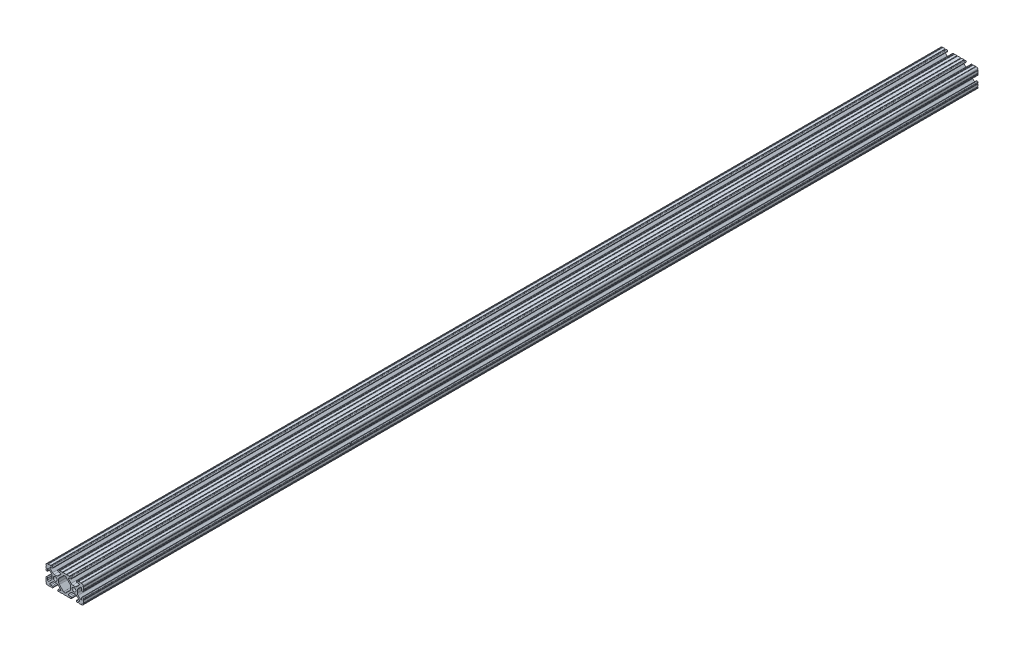
from build123d import *

# Parameters (mm, degrees)
SKETCH1_R               = 2.6035
BOSS_EXTRUDE1_DEPTH     = 609.6
SKETCH2_R               = 3.5
CUT_EXTRUDE1_DEPTH      = 9.191498123
CUT_EXTRUDE1_DEPTH_BACK = 43.608501877


with BuildPart() as part:
    # Sketch1 → Boss-Extrude1 (new body, symmetric)
    with BuildSketch(Plane.XY):
        with BuildLine():
            Line((18.01710265, 12.7), (16.98745015, 12.7))
            ThreePointArc((16.98745015, 12.7), (16.245730386, 12.392769614), (15.9385, 11.65104985))
            Line((15.9385, 11.65104985), (15.9385, 11.53922))
            ThreePointArc((15.9385, 11.53922), (16.245750844, 10.797450844), (16.98752, 10.4902))
            Line((16.98752, 10.4902), (19.116384363, 10.4902))
            ThreePointArc((19.116384363, 10.4902), (20.052502933, 9.869096983), (19.844087081, 8.765172272))
            Line((19.844087081, 8.765172272), (16.618993479, 5.455112286))
            ThreePointArc((16.618993479, 5.455112286), (15.578994274, 4.745442459), (14.344932584, 4.4958))
            Line((14.344932584, 4.4958), (11.083317835, 4.4958))
            ThreePointArc((11.083317835, 4.4958), (9.854330953, 4.743306833), (8.816955189, 5.447238587))
            Line((8.816955189, 5.447238587), (5.564154119, 8.762652677))
            ThreePointArc((5.564154119, 8.762652677), (5.352591412, 9.867473037), (6.289393385, 10.4902))
            Line((6.289393385, 10.4902), (8.41248, 10.4902))
            ThreePointArc((8.41248, 10.4902), (9.154249156, 10.797450844), (9.4615, 11.53922))
            Line((9.4615, 11.53922), (9.4615, 11.65104985))
            ThreePointArc((9.4615, 11.65104985), (9.154269614, 12.392769614), (8.41254985, 12.7))
            Line((8.41254985, 12.7), (7.38288465, 12.7))
            ThreePointArc((7.38288465, 12.7), (6.87488465, 12.192), (6.36688465, 12.7))
            Line((6.36688465, 12.7), (3.14958095, 12.7))
            ThreePointArc((3.14958095, 12.7), (2.64158095, 12.192), (2.13358095, 12.7))
            Line((2.13358095, 12.7), (-2.13358095, 12.7))
            ThreePointArc((-2.13358095, 12.7), (-2.64158095, 12.192), (-3.14958095, 12.7))
            Line((-3.14958095, 12.7), (-6.36689735, 12.7))
            ThreePointArc((-6.36689735, 12.7), (-6.87489735, 12.192), (-7.38289735, 12.7))
            Line((-7.38289735, 12.7), (-8.41254985, 12.7))
            ThreePointArc((-8.41254985, 12.7), (-9.154269614, 12.392769614), (-9.4615, 11.65104985))
            Line((-9.4615, 11.65104985), (-9.4615, 11.53922))
            ThreePointArc((-9.4615, 11.53922), (-9.154249156, 10.797450844), (-8.41248, 10.4902))
            Line((-8.41248, 10.4902), (-6.283641037, 10.4902))
            ThreePointArc((-6.283641037, 10.4902), (-5.297291557, 9.829633109), (-5.532576693, 8.666071843))
            Line((-5.532576693, 8.666071843), (-8.809985098, 5.416263103))
            ThreePointArc((-8.809985098, 5.416263103), (-9.836720513, 4.734920264), (-11.045536121, 4.4958))
            Line((-11.045536121, 4.4958), (-14.354463879, 4.4958))
            ThreePointArc((-14.354463879, 4.4958), (-15.563279487, 4.734920264), (-16.590014902, 5.416263103))
            Line((-16.590014902, 5.416263103), (-19.867423307, 8.666071843))
            ThreePointArc((-19.867423307, 8.666071843), (-20.102708443, 9.829633109), (-19.116358963, 10.4902))
            Line((-19.116358963, 10.4902), (-16.98752, 10.4902))
            ThreePointArc((-16.98752, 10.4902), (-16.245750844, 10.797450844), (-15.9385, 11.53922))
            Line((-15.9385, 11.53922), (-15.9385, 11.65104985))
            ThreePointArc((-15.9385, 11.65104985), (-16.245730386, 12.392769614), (-16.98745015, 12.7))
            Line((-16.98745015, 12.7), (-18.01711535, 12.7))
            ThreePointArc((-18.01711535, 12.7), (-18.52511535, 12.192), (-19.03311535, 12.7))
            Line((-19.03311535, 12.7), (-22.2504, 12.7))
            ThreePointArc((-22.2504, 12.7), (-22.758323491, 12.192000006), (-23.266399977, 12.699846982))
            ThreePointArc((-23.266399977, 12.699846982), (-24.782522516, 12.082522516), (-25.399846982, 10.566399977))
            ThreePointArc((-25.399846982, 10.566399977), (-24.892000006, 10.058323491), (-25.4, 9.5504))
            Line((-25.4, 9.5504), (-25.4, 6.3330836))
            ThreePointArc((-25.4, 6.3330836), (-24.892, 5.8250836), (-25.4, 5.3170836))
            Line((-25.4, 5.3170836), (-25.4, 4.237520184))
            ThreePointArc((-25.4, 4.237520184), (-25.107393763, 3.531106237), (-24.400979816, 3.2385))
            Line((-24.400979816, 3.2385), (-24.23922, 3.2385))
            ThreePointArc((-24.23922, 3.2385), (-23.497450844, 3.545750844), (-23.1902, 4.28752))
            Line((-23.1902, 4.28752), (-23.1902, 6.334741132))
            ThreePointArc((-23.1902, 6.334741132), (-22.556026952, 7.286023527), (-21.434002553, 7.066535717))
            Line((-21.434002553, 7.066535717), (-18.147950853, 3.808156468))
            ThreePointArc((-18.147950853, 3.808156468), (-17.452759693, 2.774838327), (-17.208501877, 1.553619571))
            Line((-17.208501877, 1.553619571), (-17.208501877, -1.695179196))
            ThreePointArc((-17.208501877, -1.695179196), (-17.450738657, -2.911536421), (-18.140486065, -3.942289578))
            Line((-18.140486065, -3.942289578), (-21.431579576, -7.227386226))
            ThreePointArc((-21.431579576, -7.227386226), (-22.55444896, -7.449940594), (-23.1902, -6.498002195))
            Line((-23.1902, -6.498002195), (-23.1902, -4.28752))
            ThreePointArc((-23.1902, -4.28752), (-23.497450844, -3.545750844), (-24.23922, -3.2385))
            Line((-24.23922, -3.2385), (-24.35098, -3.2385))
            ThreePointArc((-24.35098, -3.2385), (-25.092749156, -3.545750844), (-25.4, -4.28752))
            Line((-25.4, -4.28752), (-25.4, -5.3171344))
            ThreePointArc((-25.4, -5.3171344), (-24.892, -5.8251344), (-25.4, -6.3331344))
            Line((-25.4, -6.3331344), (-25.4, -9.5504))
            ThreePointArc((-25.4, -9.5504), (-24.892000006, -10.058323491), (-25.399846982, -10.566399977))
            ThreePointArc((-25.399846982, -10.566399977), (-24.782522516, -12.082522516), (-23.266399977, -12.699846982))
            ThreePointArc((-23.266399977, -12.699846982), (-22.758323491, -12.192000006), (-22.2504, -12.7))
            Line((-22.2504, -12.7), (-19.03308995, -12.7))
            ThreePointArc((-19.03308995, -12.7), (-18.52508995, -12.192), (-18.01708995, -12.7))
            Line((-18.01708995, -12.7), (-16.9874692, -12.7))
            ThreePointArc((-16.9874692, -12.7), (-16.245700044, -12.392749156), (-15.9384492, -11.65098))
            Line((-15.9384492, -11.65098), (-15.9384492, -11.53922))
            ThreePointArc((-15.9384492, -11.53922), (-16.245700044, -10.797450844), (-16.9874692, -10.4902))
            Line((-16.9874692, -10.4902), (-19.116358963, -10.4902))
            ThreePointArc((-19.116358963, -10.4902), (-20.055197748, -9.862578342), (-19.834124023, -8.755124678))
            Line((-19.834124023, -8.755124678), (-16.49660751, -5.423689618))
            ThreePointArc((-16.49660751, -5.423689618), (-15.467274017, -4.736928798), (-14.253591699, -4.4958))
            Line((-14.253591699, -4.4958), (-11.146408301, -4.4958))
            ThreePointArc((-11.146408301, -4.4958), (-9.932725983, -4.736928798), (-8.90339249, -5.423689618))
            Line((-8.90339249, -5.423689618), (-5.565875977, -8.755124678))
            ThreePointArc((-5.565875977, -8.755124678), (-5.344802252, -9.862578342), (-6.283641037, -10.4902))
            Line((-6.283641037, -10.4902), (-8.4125308, -10.4902))
            ThreePointArc((-8.4125308, -10.4902), (-9.154299956, -10.797450844), (-9.4615508, -11.53922))
            Line((-9.4615508, -11.53922), (-9.4615508, -11.65098))
            ThreePointArc((-9.4615508, -11.65098), (-9.154299956, -12.392749156), (-8.4125308, -12.7))
            Line((-8.4125308, -12.7), (-7.38287195, -12.7))
            ThreePointArc((-7.38287195, -12.7), (-6.87487195, -12.192), (-6.36687195, -12.7))
            Line((-6.36687195, -12.7), (-3.14960635, -12.7))
            ThreePointArc((-3.14960635, -12.7), (-2.64160635, -12.192), (-2.13360635, -12.7))
            Line((-2.13360635, -12.7), (2.13360635, -12.7))
            ThreePointArc((2.13360635, -12.7), (2.64159365, -12.1920127), (3.14958095, -12.7))
            Line((3.14958095, -12.7), (6.36691005, -12.7))
            ThreePointArc((6.36691005, -12.7), (6.87491005, -12.192), (7.38291005, -12.7))
            Line((7.38291005, -12.7), (8.4125308, -12.7))
            ThreePointArc((8.4125308, -12.7), (9.154299956, -12.392749156), (9.4615508, -11.65098))
            Line((9.4615508, -11.65098), (9.4615508, -11.53922))
            ThreePointArc((9.4615508, -11.53922), (9.154299956, -10.797450844), (8.4125308, -10.4902))
            Line((8.4125308, -10.4902), (6.289393385, -10.4902))
            ThreePointArc((6.289393385, -10.4902), (5.231590322, -9.783049717), (5.480677245, -8.535265862))
            Line((5.480677245, -8.535265862), (8.597933595, -5.423689618))
            ThreePointArc((8.597933595, -5.423689618), (9.627267088, -4.736928798), (10.840949406, -4.4958))
            Line((10.840949406, -4.4958), (14.102564155, -4.4958))
            ThreePointArc((14.102564155, -4.4958), (15.215927525, -4.697410182), (16.187895372, -5.276636531))
            Line((16.187895372, -5.276636531), (19.868247549, -8.482246082))
            ThreePointArc((19.868247549, -8.482246082), (20.188435806, -9.746879864), (19.116384363, -10.4902))
            Line((19.116384363, -10.4902), (16.9874692, -10.4902))
            ThreePointArc((16.9874692, -10.4902), (16.245700044, -10.797450844), (15.9384492, -11.53922))
            Line((15.9384492, -11.53922), (15.9384492, -11.65098))
            ThreePointArc((15.9384492, -11.65098), (16.245700044, -12.392749156), (16.9874692, -12.7))
            Line((16.9874692, -12.7), (18.01710265, -12.7))
            ThreePointArc((18.01710265, -12.7), (18.52510265, -12.192), (19.03310265, -12.7))
            Line((19.03310265, -12.7), (22.2504, -12.7))
            ThreePointArc((22.2504, -12.7), (22.758323491, -12.192000006), (23.266399977, -12.699846982))
            ThreePointArc((23.266399977, -12.699846982), (24.782522516, -12.082522516), (25.399846982, -10.566399977))
            ThreePointArc((25.399846982, -10.566399977), (24.892000006, -10.058323492), (25.4, -9.550400001))
            Line((25.4, -9.550400001), (25.4, -6.333083592))
            ThreePointArc((25.4, -6.333083592), (24.892000001, -5.825083593), (25.4, -5.317083593))
            Line((25.4, -5.317083593), (25.4, -4.237520184))
            ThreePointArc((25.4, -4.237520184), (25.107393763, -3.531106237), (24.400979816, -3.2385))
            Line((24.400979816, -3.2385), (24.189220184, -3.2385))
            ThreePointArc((24.189220184, -3.2385), (23.482806237, -3.531106237), (23.1902, -4.237520184))
            Line((23.1902, -4.237520184), (23.1902, -6.155876159))
            ThreePointArc((23.1902, -6.155876159), (22.62232736, -7.038258539), (21.583974541, -6.886926384))
            Line((21.583974541, -6.886926384), (18.29817066, -4.024970844))
            ThreePointArc((18.29817066, -4.024970844), (17.493730985, -2.946044689), (17.208501877, -1.630807374))
            Line((17.208501877, -1.630807374), (17.208501877, 1.630807374))
            ThreePointArc((17.208501877, 1.630807374), (17.442348332, 2.82673414), (18.109440981, 3.846495088))
            Line((18.109440981, 3.846495088), (21.526346532, 7.353420386))
            ThreePointArc((21.526346532, 7.353420386), (22.585896263, 7.574939077), (23.1902, 6.676867167))
            Line((23.1902, 6.676867167), (23.1902, 4.237520184))
            ThreePointArc((23.1902, 4.237520184), (23.482806237, 3.531106237), (24.189220184, 3.2385))
            Line((24.189220184, 3.2385), (24.400979816, 3.2385))
            ThreePointArc((24.400979816, 3.2385), (25.107393763, 3.531106237), (25.4, 4.237520184))
            Line((25.4, 4.237520184), (25.4, 5.3170836))
            ThreePointArc((25.4, 5.3170836), (24.891949193, 5.825134407), (25.4, 6.333185215))
            Line((25.4, 6.333185215), (25.4, 9.550400015))
            ThreePointArc((25.4, 9.550400015), (24.892000013, 10.058323498), (25.399846982, 10.566399977))
            ThreePointArc((25.399846982, 10.566399977), (24.782522516, 12.082522516), (23.266399977, 12.699846982))
            ThreePointArc((23.266399977, 12.699846982), (22.758323491, 12.192000006), (22.2504, 12.7))
            Line((22.2504, 12.7), (19.03310265, 12.7))
            ThreePointArc((19.03310265, 12.7), (18.52510265, 12.192), (18.01710265, 12.7))
        make_face()
        with Locations((-12.7, 0)):
            Circle(SKETCH1_R, mode=Mode.SUBTRACT)
        with Locations((12.7, 0)):
            Circle(SKETCH1_R, mode=Mode.SUBTRACT)
        with BuildLine():
            Line((-7.259513935, -3.869413038), (-1.545748891, -9.572766749))
            ThreePointArc((-1.545748891, -9.572766749), (-1.035199478, -9.913400116), (-0.433213048, -10.033))
            Line((-0.433213048, -10.033), (0.433213048, -10.033))
            ThreePointArc((0.433213048, -10.033), (1.035199478, -9.913400116), (1.545748891, -9.572766749))
            Line((1.545748891, -9.572766749), (7.259513935, -3.869413038))
            ThreePointArc((7.259513935, -3.869413038), (7.949261343, -2.838659881), (8.191498123, -1.622302656))
            Line((8.191498123, -1.622302656), (8.191498123, 1.622302656))
            ThreePointArc((8.191498123, 1.622302656), (7.955573352, 2.823327967), (7.282860769, 3.845864069))
            Line((7.282860769, 3.845864069), (1.675572808, 9.561086461))
            ThreePointArc((1.675572808, 9.561086461), (1.161034429, 9.910236611), (0.551456936, 10.033))
            Line((0.551456936, 10.033), (-0.395199982, 10.033))
            ThreePointArc((-0.395199982, 10.033), (-0.994772524, 9.914396349), (-1.50403329, 9.576450301))
            Line((-1.50403329, 9.576450301), (-7.252049147, 3.876839553))
            ThreePointArc((-7.252049147, 3.876839553), (-7.947240307, 2.843521412), (-8.191498123, 1.622302656))
            Line((-8.191498123, 1.622302656), (-8.191498123, -1.622302656))
            ThreePointArc((-8.191498123, -1.622302656), (-7.949261343, -2.838659881), (-7.259513935, -3.869413038))
        make_face(mode=Mode.SUBTRACT)
    extrude(amount=BOSS_EXTRUDE1_DEPTH, both=True)

    # Sketch2 → Cut-Extrude1 (cut, two sides)
    with BuildSketch(Plane(origin=(17.208501877, 0, 0), x_dir=(0, 0, -1), z_dir=(1, 0, 0))) as cut_extrude1_sk:
        with Locations((244.47, 0)):
            Circle(SKETCH2_R)
        with Locations((-244.47, 0)):
            Circle(SKETCH2_R)
    extrude(amount=CUT_EXTRUDE1_DEPTH, mode=Mode.SUBTRACT)
    extrude(cut_extrude1_sk.sketch, amount=-CUT_EXTRUDE1_DEPTH_BACK, mode=Mode.SUBTRACT)


solid = part.part
